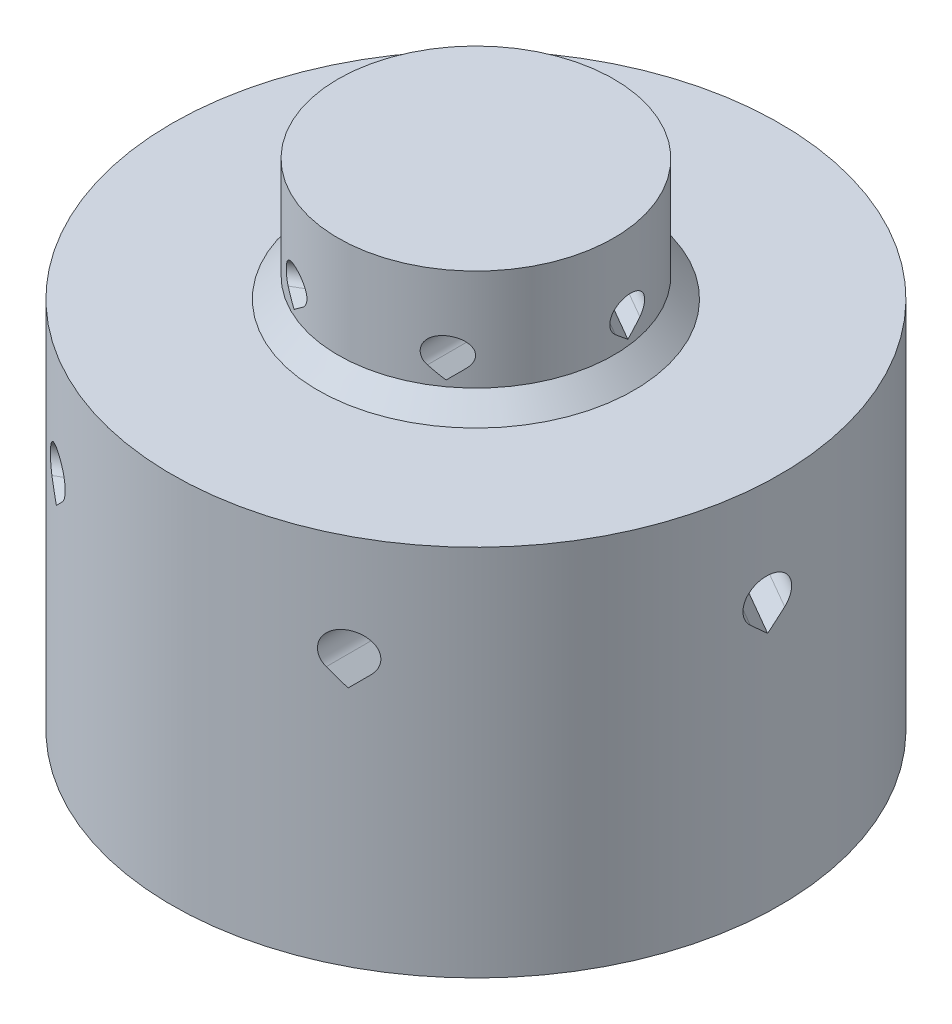
from build123d import *

# Parameters (mm, degrees)
SKETCH3_W          = 4.445
SKETCH3_H          = 1.5875
CUT_EXTRUDE1_DEPTH = 29.136842118
CIRPATTERN1_COUNT  = 6
CUT_EXTRUDE2_DEPTH = 29.136842118
CIRPATTERN2_COUNT  = 6


with BuildPart() as part:
    # Sketch1 → Revolve1 (revolve)
    with BuildSketch(Plane.XY):
        Polygon((-5.3975, 0), (-5.3975, -3.96875), (-6.19125, -4.7625), (-11.90625, -4.7625), (-11.90625, -7.1755), (-6.35, -7.1755), (-6.35, -7.9375), (-4.60375, -7.9375), (-4.60375, -13.346282015), (-3.33375, -14.616282015), (-3.33375, -16.8275), (-2.54, -16.8275), (-2.54, -14.2875), (-3.81, -13.0175), (-3.81, -1.5875), (-4.445, -1.5875), (-4.445, 0), align=None)
    revolve(axis=Axis((0, -1.5875, 0), (0, -1, 0)))

    # Sketch2 → Revolve2 (revolve)
    with BuildSketch(Plane.XY):
        Polygon((-6.35, -7.9375), (-6.35, -14.2875), (-4.445, -16.1925), (-4.445, -22.5425), (-6.35, -22.5425), (-6.35, -19.3675), (-7.3152, -19.3675), (-7.3152, -17.3863), (-10.3886, -17.3863), (-10.3886, -19.3675), (-11.90625, -19.3675), (-11.90625, -7.1755), (-6.35, -7.1755), align=None)
    revolve(axis=Axis((0, -1.5875, 0), (0, -1, 0)))

    # Sketch3 → Revolve3 (revolve)
    with BuildSketch(Plane.XY):
        with Locations((-2.2225, -0.79375)):
            Rectangle(SKETCH3_W, SKETCH3_H)
    revolve(axis=Axis((0, -1.5875, 0), (0, 1, 0)))

    # Sketch8 → Cut-Extrude1 (cut, through all)
    with BuildSketch(Plane.XY):
        with BuildLine():
            Line((-3.1877, -3.7375651), (-3.62773255, -3.29753255))
            ThreePointArc((-3.62773255, -3.29753255), (-3.1877, -2.2352), (-2.74766745, -3.29753255))
            Line((-2.74766745, -3.29753255), (-3.1877, -3.7375651))
        make_face()
    cut_extrude1 = extrude(amount=-CUT_EXTRUDE1_DEPTH, mode=Mode.SUBTRACT)

    # CirPattern1: Cut-Extrude1 ×6 about axis
    cirpattern1_axis = Axis((0, 42.935, 0), (0, -1, 0))
    for i in range(1, CIRPATTERN1_COUNT):
        add(cut_extrude1.rotate(cirpattern1_axis, i * 360 / CIRPATTERN1_COUNT), mode=Mode.SUBTRACT)

    # Sketch9 → Cut-Extrude2 (cut, through all)
    with BuildSketch(Plane.XY):
        with BuildLine():
            Line((-5.5372, -9.912472783), (-6.111936392, -9.337736392))
            ThreePointArc((-6.111936392, -9.337736392), (-5.5372, -7.9502), (-4.962463608, -9.337736392))
            Line((-4.962463608, -9.337736392), (-5.5372, -9.912472783))
        make_face()
    cut_extrude2 = extrude(amount=-CUT_EXTRUDE2_DEPTH, mode=Mode.SUBTRACT)

    # CirPattern2: Cut-Extrude2 ×6 about axis
    cirpattern2_axis = Axis((0, 42.935, 0), (0, -1, 0))
    for i in range(1, CIRPATTERN2_COUNT):
        add(cut_extrude2.rotate(cirpattern2_axis, i * 360 / CIRPATTERN2_COUNT), mode=Mode.SUBTRACT)


solid = part.part
